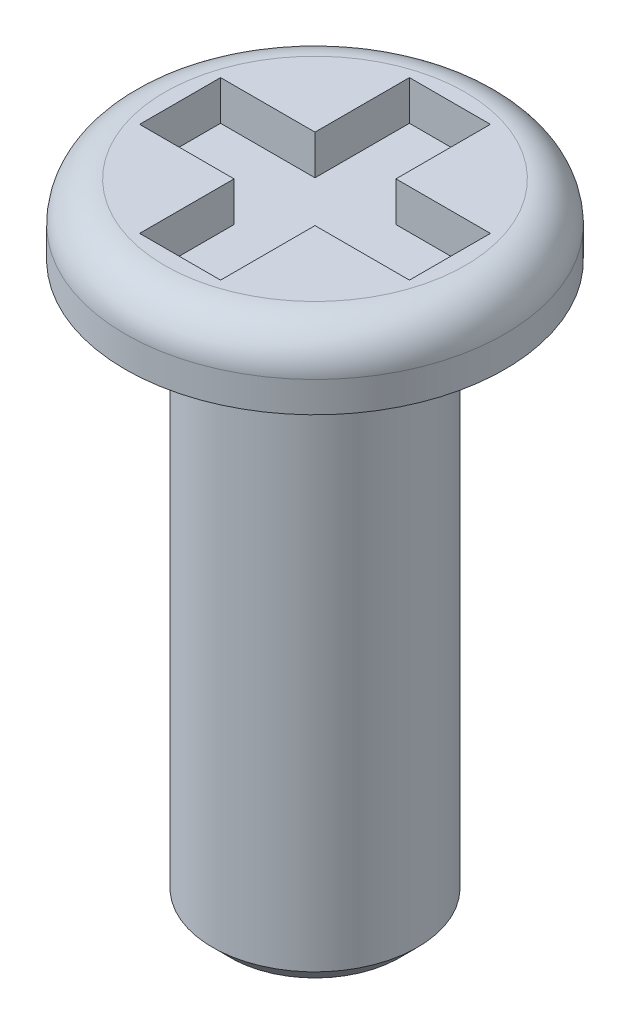
from build123d import *

# Parameters (mm, degrees)
SKETCH1_W           = 2.6797
SKETCH1_H           = 0.9906
SKETCH2_R           = 1.4478
BOSS_EXTRUDE1_DEPTH = 7.9375
CUT_EXTRUDE1_DEPTH  = 0.5588
CHAMFER1_SIZE       = 0.254
FILLET1_R           = 0.254
FILLET2_R           = 0.5588


with BuildPart() as part:
    # Sketch1 → Revolve1 (revolve)
    with BuildSketch(Plane.XY):
        with Locations((1.33985, 0.4953)):
            Rectangle(SKETCH1_W, SKETCH1_H)
    revolve(axis=Axis((0, 0.9906, 0), (0, -1, 0)))

    # Sketch2 → Boss-Extrude1 (add)
    with BuildSketch(Plane.XZ):
        Circle(SKETCH2_R)
    extrude(amount=BOSS_EXTRUDE1_DEPTH)

    # Sketch3 → Cut-Extrude1 (cut)
    with BuildSketch(Plane(origin=(0, 0.9906, 0), x_dir=(-1, 0, 0), z_dir=(0, 1, 0))):
        Polygon((-0.5715, -0.5715), (-0.5715, -1.905), (0.5715, -1.905), (0.5715, -0.5715), (1.905, -0.5715), (1.905, 0.5715), (0.5715, 0.5715), (0.5715, 1.905), (-0.5715, 1.905), (-0.5715, 0.5715), (-1.905, 0.5715), (-1.905, -0.5715), align=None)
    extrude(amount=-CUT_EXTRUDE1_DEPTH, mode=Mode.SUBTRACT)

    # Chamfer1
    chamfer1_edges = [part.edges().sort_by_distance(p)[0] for p in [
        (-1.4478, -7.9375, 0),
    ]]
    chamfer(chamfer1_edges, length=CHAMFER1_SIZE)

    # Fillet1
    fillet1_edges = [part.edges().sort_by_distance(p)[0] for p in [
        (-1.4478, 0, 0),
    ]]
    fillet(fillet1_edges, radius=FILLET1_R)

    # Fillet2
    fillet2_edges = [part.edges().sort_by_distance(p)[0] for p in [
        (-2.6797, 0.9906, 0),
    ]]
    fillet(fillet2_edges, radius=FILLET2_R)


solid = part.part
